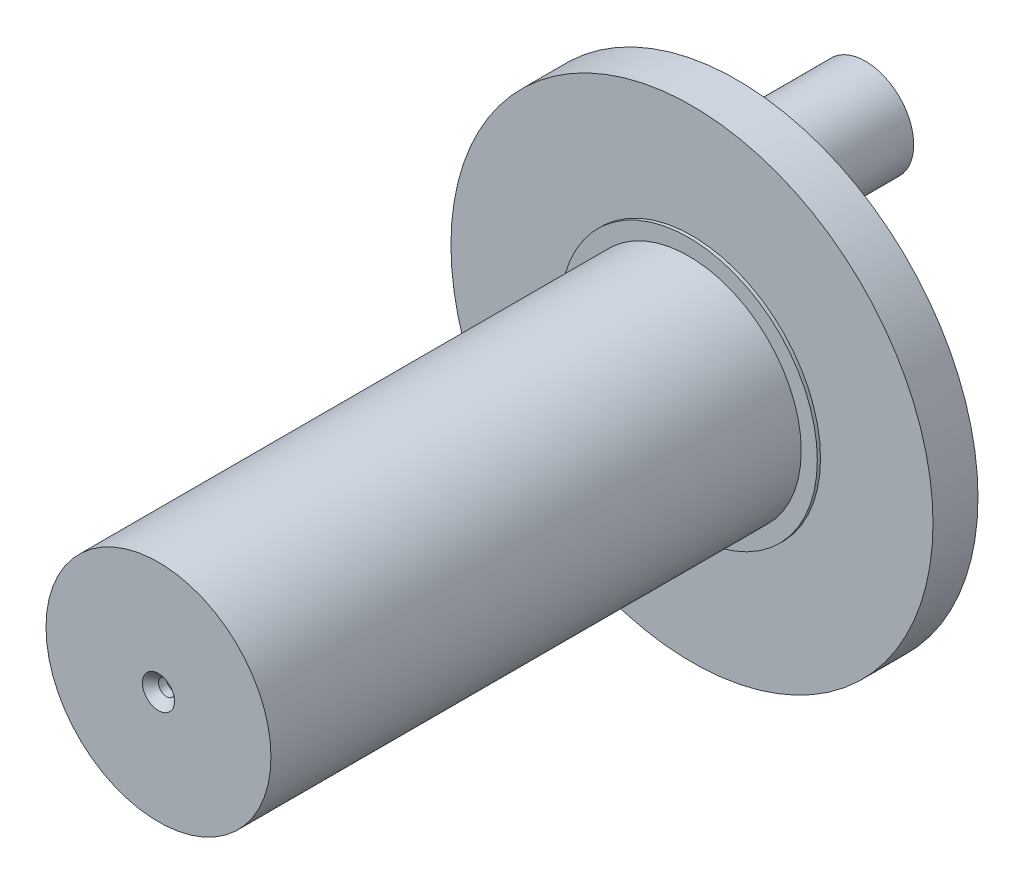
from build123d import *

# Parameters (mm, degrees)
SKETCH1_R                                       = 15
BOSS_EXTRUDE1_DEPTH                             = 2.8
SKETCH3_R                                       = 8
BOSS_EXTRUDE3_DEPTH                             = 0.2
SKETCH2_R                                       = 7
BOSS_EXTRUDE2_DEPTH                             = 33
SKETCH4_R                                       = 5
BOSS_EXTRUDE4_DEPTH                             = 0.4
SKETCH5_R                                       = 3
BOSS_EXTRUDE5_DEPTH                             = 8
CSK_FOR_M2_OVAL_HEAD_MACHINE_SCREW1_D           = 1
CSK_FOR_M2_OVAL_HEAD_MACHINE_SCREW1_DEPTH       = 1
CSK_FOR_M2_OVAL_HEAD_MACHINE_SCREW1_CSINK_D     = 2
CSK_FOR_M2_OVAL_HEAD_MACHINE_SCREW1_CSINK_ANGLE = 90
CSK_FOR_M2_OVAL_HEAD_MACHINE_SCREW1_TIP         = 0.30043031


with BuildPart() as part:
    # Sketch1 → Boss-Extrude1 (new body)
    with BuildSketch(Plane.XY):
        Circle(SKETCH1_R)
    extrude(amount=BOSS_EXTRUDE1_DEPTH)

    # Sketch3 → Boss-Extrude3 (add)
    with BuildSketch(Plane.XY.offset(2.8)):
        Circle(SKETCH3_R)
    extrude(amount=BOSS_EXTRUDE3_DEPTH)

    # Sketch2 → Boss-Extrude2 (add)
    with BuildSketch(Plane.XY.offset(3)):
        Circle(SKETCH2_R)
    extrude(amount=BOSS_EXTRUDE2_DEPTH)

    # Sketch4 → Boss-Extrude4 (add)
    with BuildSketch(Plane(origin=(0, 0, 0), x_dir=(-1, 0, 0), z_dir=(0, 0, -1))):
        with Locations(Location((0, 9, 0), (0, 0, 180))):  # turned: the seam where the file's is
            Circle(SKETCH4_R)
    extrude(amount=BOSS_EXTRUDE4_DEPTH)

    # Sketch5 → Boss-Extrude5 (add)
    with BuildSketch(Plane(origin=(0, 0, 0), x_dir=(-1, 0, 0), z_dir=(0, 0, -1))):
        with Locations((0, 9)):
            Circle(SKETCH5_R)
    extrude(amount=BOSS_EXTRUDE5_DEPTH)

    # CSK for M2 Oval Head Machine Screw1
    with Locations(Plane.XY.offset(36)):
        with Locations((0, 0)):
            CounterSinkHole(CSK_FOR_M2_OVAL_HEAD_MACHINE_SCREW1_D / 2, CSK_FOR_M2_OVAL_HEAD_MACHINE_SCREW1_CSINK_D / 2, depth=CSK_FOR_M2_OVAL_HEAD_MACHINE_SCREW1_DEPTH, counter_sink_angle=CSK_FOR_M2_OVAL_HEAD_MACHINE_SCREW1_CSINK_ANGLE)
            with Locations((0, 0, -(CSK_FOR_M2_OVAL_HEAD_MACHINE_SCREW1_DEPTH + CSK_FOR_M2_OVAL_HEAD_MACHINE_SCREW1_TIP / 2))):  # 118° drill point
                Cone(0, CSK_FOR_M2_OVAL_HEAD_MACHINE_SCREW1_D / 2, CSK_FOR_M2_OVAL_HEAD_MACHINE_SCREW1_TIP, mode=Mode.SUBTRACT)


solid = part.part
